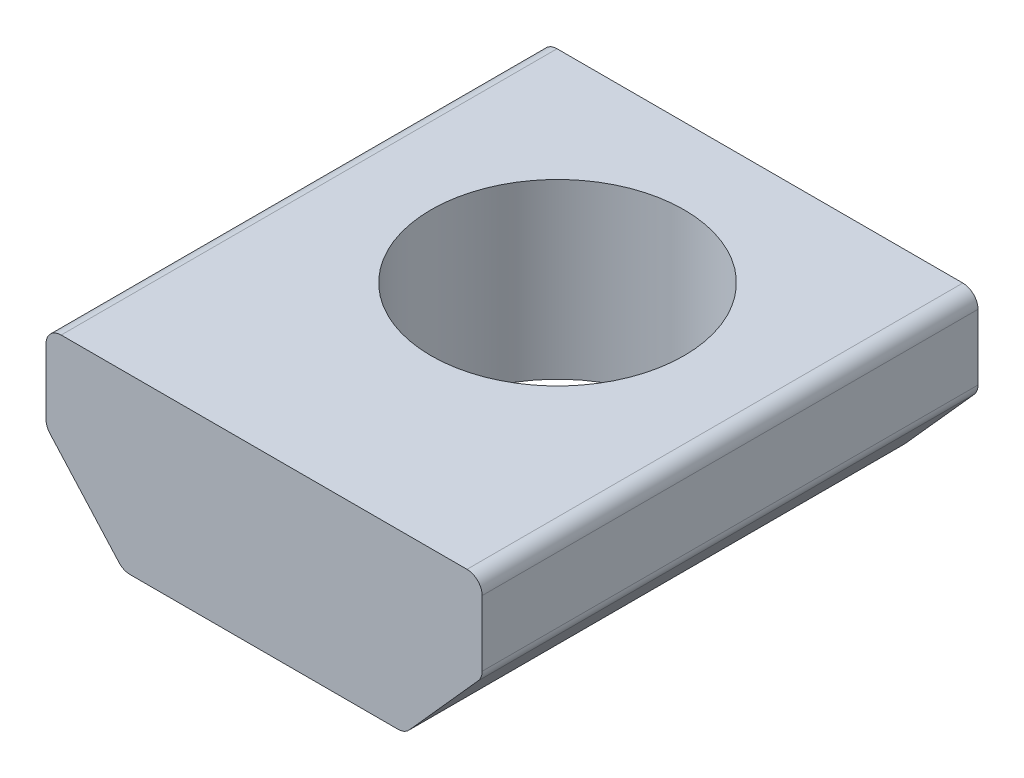
from build123d import *

# Parameters (mm, degrees)
EXTRUDE1_DEPTH     = 12.446
SKETCH2_R          = 3.175
CUT_EXTRUDE1_DEPTH = 12.446


with BuildPart() as part:
    # Sketch1 → Extrude1 (new body)
    with BuildSketch(Plane.XY):
        with BuildLine():
            Line((-5.0927, 0), (5.0927, 0))
            ThreePointArc((5.0927, 0), (5.362107684, -0.111592316), (5.4737, -0.381))
            Line((5.4737, -0.381), (5.4737, -2.026133402))
            ThreePointArc((5.4737, -2.026133402), (5.448607976, -2.162113227), (5.37663694, -2.280182243))
            Line((5.37663694, -2.280182243), (3.644187879, -4.216448841))
            ThreePointArc((3.644187879, -4.216448841), (3.515763625, -4.3102172), (3.360250938, -4.3434))
            Line((3.360250938, -4.3434), (-3.360250938, -4.3434))
            ThreePointArc((-3.360250938, -4.3434), (-3.515763625, -4.3102172), (-3.644187879, -4.216448841))
            Line((-3.644187879, -4.216448841), (-5.37663694, -2.280182243))
            ThreePointArc((-5.37663694, -2.280182243), (-5.448607976, -2.162113227), (-5.4737, -2.026133402))
            Line((-5.4737, -2.026133402), (-5.4737, -0.381))
            ThreePointArc((-5.4737, -0.381), (-5.362107684, -0.111592316), (-5.0927, 0))
        make_face()
    extrude(amount=EXTRUDE1_DEPTH)

    # Sketch2 → Cut-Extrude1 (cut)
    with BuildSketch(Plane(origin=(0, 0, 0), x_dir=(-1, 0, 0), z_dir=(0, 1, 0))):
        with Locations((0, 5.08)):
            Circle(SKETCH2_R)
    extrude(amount=-CUT_EXTRUDE1_DEPTH, mode=Mode.SUBTRACT)


solid = part.part
